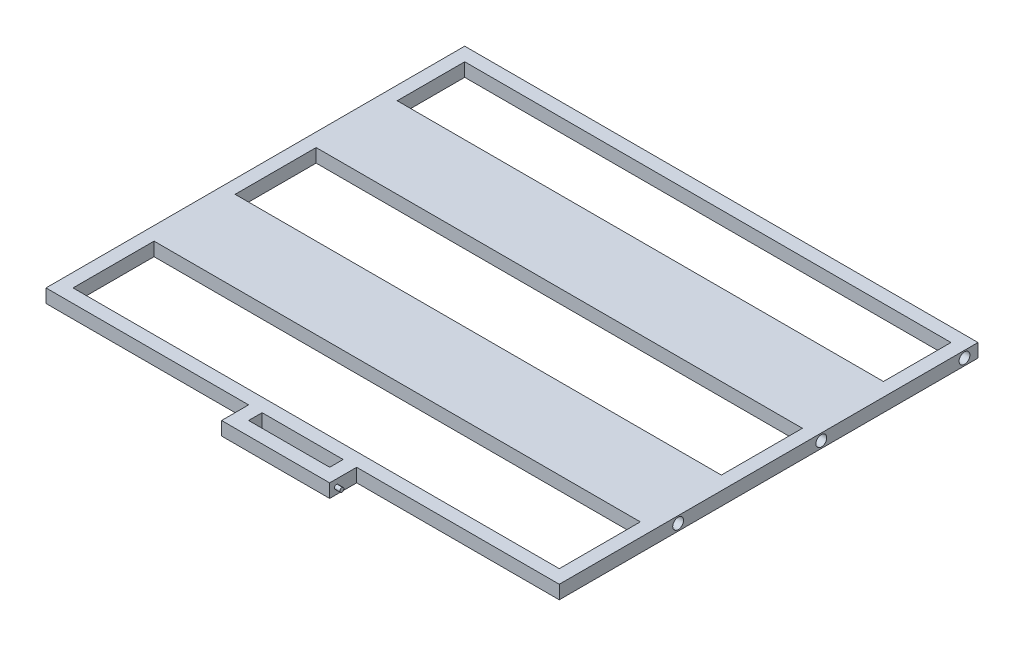
from build123d import *

# Parameters (mm, degrees)
CROQUIS1_W              = 150
CROQUIS1_H              = 25
CROQUIS1_W_2            = 900
CROQUIS1_H_2            = 150
SALIENTE_EXTRUIR1_DEPTH = 25
SALIENTE_EXTRUIR2_DEPTH = 10
SALIENTE_EXTRUIR3_REACH = 927
CROQUIS3_W              = 25
CROQUIS3_H              = 25
CROQUIS4_W              = 25
CROQUIS4_H              = 25
CORTAR_EXTRUIR1_DEPTH   = 951
CROQUIS5_R              = 10
CORTAR_EXTRUIR2_DEPTH   = 20


with BuildPart() as part:
    # Croquis1 → Saliente-Extruir1 (new body)
    with BuildSketch(Plane(origin=(0, 0, 0), x_dir=(1, 0, 0), z_dir=(0, 1, 0))):
        Polygon((-100, -450), (100, -450), (100, -400), (475, -400), (475, 400), (-475, 400), (-475, -400), (-100, -400), align=None)
        with Locations((0, -412.5)):
            Rectangle(CROQUIS1_W, CROQUIS1_H, mode=Mode.SUBTRACT)
        with Locations((0, -300)):
            Rectangle(CROQUIS1_W_2, CROQUIS1_H_2, mode=Mode.SUBTRACT)
        Rectangle(CROQUIS1_W_2, CROQUIS1_H_2, mode=Mode.SUBTRACT)
        with Locations((0, 300)):
            Rectangle(CROQUIS1_W_2, CROQUIS1_H_2, mode=Mode.SUBTRACT)
    extrude(amount=SALIENTE_EXTRUIR1_DEPTH)

    # Croquis2 → Saliente-Extruir2 (add)
    with BuildSketch(Plane(origin=(100, 0, 0), x_dir=(0, 0, -1), z_dir=(1, 0, 0))):
        with BuildLine():
            ThreePointArc((-433.75, 12.5), (-436.064937129, 15.964548247), (-440.151650429, 15.151650429))
            Line((-440.151650429, 15.151650429), (-434.848349571, 9.848349571))
            ThreePointArc((-434.848349571, 9.848349571), (-434.035451753, 11.064937129), (-433.75, 12.5))
        make_face()
        with BuildLine():
            Line((-434.848349571, 9.848349571), (-440.151650429, 15.151650429))
            ThreePointArc((-440.151650429, 15.151650429), (-440.151650429, 9.848349571), (-434.848349571, 9.848349571))
        make_face()
    extrude(amount=SALIENTE_EXTRUIR2_DEPTH)

    # Croquis3 → Saliente-Extruir3 (add, up to next)
    with BuildSketch(Plane(origin=(-450, 0, 0), x_dir=(0, 0, -1), z_dir=(1, 0, 0)), mode=Mode.PRIVATE) as saliente_extruir3_sk1:
        with Locations((362.5, 12.5)):
            Rectangle(CROQUIS3_W, CROQUIS3_H)
    saliente_extruir3_tool1 = extrude(saliente_extruir3_sk1.sketch, amount=SALIENTE_EXTRUIR3_REACH, mode=Mode.PRIVATE) - part.part
    add(saliente_extruir3_tool1.solids().sort_by_distance((-450, 12.5, -362.5))[0])

    # Croquis4 → Cortar-Extruir1 (cut, through all)
    with BuildSketch(Plane.ZY.offset(475)):
        with Locations((-387.5, 12.5)):
            Rectangle(CROQUIS4_W, CROQUIS4_H)
    extrude(amount=-CORTAR_EXTRUIR1_DEPTH, mode=Mode.SUBTRACT)

    # Croquis5 → Cortar-Extruir2 (cut)
    with BuildSketch(Plane(origin=(475, 0, 0), x_dir=(0, 0, -1), z_dir=(1, 0, 0))):
        with Locations((350, 12.5)):
            Circle(CROQUIS5_R)
        with Locations((85, 12.5)):
            Circle(CROQUIS5_R)
        with Locations((-180, 12.5)):
            Circle(CROQUIS5_R)
    cortar_extruir2 = extrude(amount=-CORTAR_EXTRUIR2_DEPTH, mode=Mode.SUBTRACT)

    # Simetría1: Cortar-Extruir2 across plane
    add(cortar_extruir2.mirror(Plane(origin=(-1.209663813, -319.213288435, 1311.891688688), x_dir=(0, 0, 1), z_dir=(1, 0, 0))), mode=Mode.SUBTRACT)


solid = part.part
